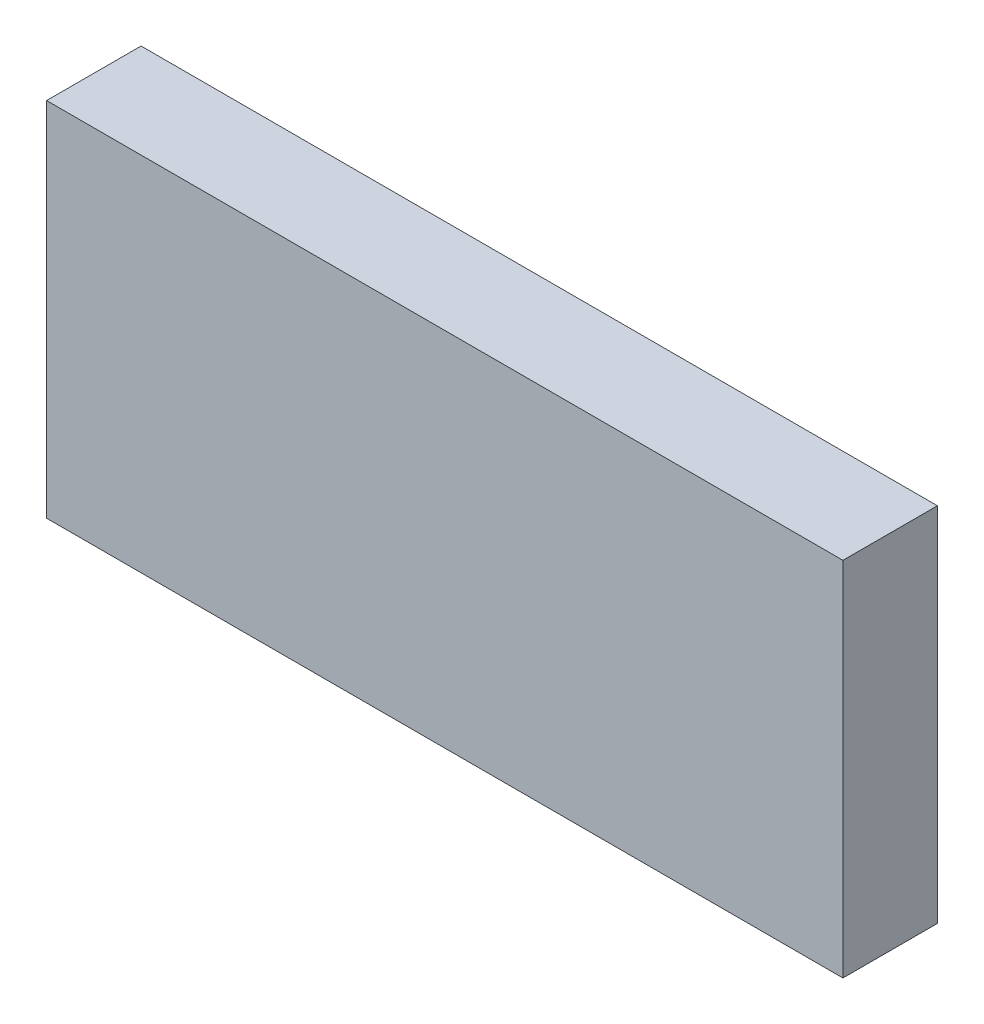
from build123d import *

# Parameters (mm, degrees)
SKETCH1_W           = 84.297670299
SKETCH1_H           = 38.292622135
BOSS_EXTRUDE1_DEPTH = 10


with BuildPart() as part:
    # Sketch1 → Boss-Extrude1 (new body)
    with BuildSketch(Plane.XY):
        with Locations((42.14883515, 19.146311068)):
            Rectangle(SKETCH1_W, SKETCH1_H)
    extrude(amount=BOSS_EXTRUDE1_DEPTH)


solid = part.part
